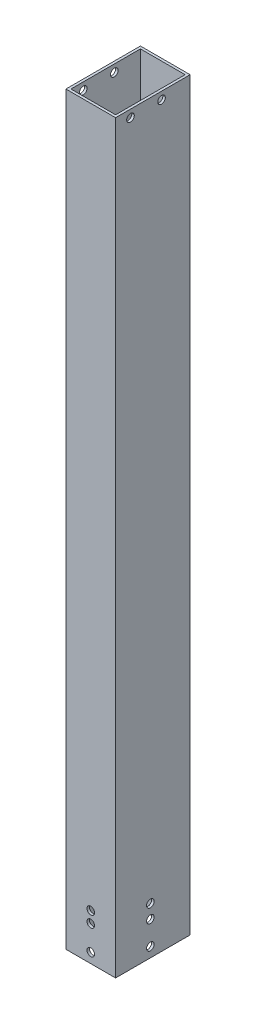
from build123d import *

# Parameters (mm, degrees)
SKETCH_1_W                = 20
SKETCH_1_H                = 30
EXTRUDE_1_DEPTH           = 150
SKETCH_2_W                = 18
SKETCH_2_H                = 28
CUT_EXTRUDE_1_DEPTH       = 301
SKETCH_3_R                = 1.525
CUT_EXTRUDE_2_DEPTH       = 21
SKETCH_4_R                = 1.525
CUT_EXTRUDE_3_DEPTH       = 31
SKETCH_5_R                = 1.525
CUT_EXTRUDE_4_DEPTH       = 31
SKETCH_6_OUTSIDE_W        = 92.432
SKETCH_6_OUTSIDE_H        = 362.432
SKETCH_6_OUTSIDE_W_2      = 30
SKETCH_6_OUTSIDE_H_2      = 300
SKETCH_6_OUTSIDE_R        = 1.525
CUT_EXTRUDE_6_DEPTH       = 21
CUT_EXTRUDE_8_REACH       = 32
SKETCH_9_R                = 1.525
SKETCH_10_R               = 1.525
CUT_EXTRUDE_9_DEPTH       = 1
CUT_EXTRUDE_9_DEPTH_BACK  = 21
SKETCH_11_R               = 1.525
CUT_EXTRUDE_10_DEPTH      = 20
CUT_EXTRUDE_10_DEPTH_BACK = 2


with BuildPart() as part:
    # 草图1 → 凸台-拉伸1 (new body, symmetric)
    with BuildSketch(Plane(origin=(0, 0, 0), x_dir=(1, 0, 0), z_dir=(0, 1, 0))):
        Rectangle(SKETCH_1_W, SKETCH_1_H)
    extrude(amount=EXTRUDE_1_DEPTH, both=True)

    # 草图2 → 切除-拉伸1 (cut, through all)
    with BuildSketch(Plane(origin=(0, 150, 0), x_dir=(1, 0, 0), z_dir=(0, 1, 0))):
        Rectangle(SKETCH_2_W, SKETCH_2_H)
    extrude(amount=-CUT_EXTRUDE_1_DEPTH, mode=Mode.SUBTRACT)

    # 草图3 → 切除-拉伸2 (cut, through all)
    with BuildSketch(Plane(origin=(10, 0, 0), x_dir=(0, 0, -1), z_dir=(1, 0, 0))):
        with Locations((-1, -146)):
            Circle(SKETCH_3_R)
    extrude(amount=-CUT_EXTRUDE_2_DEPTH, mode=Mode.SUBTRACT)

    # 草图4 → 切除-拉伸3 (cut, through all)
    with BuildSketch(Plane.XY.offset(15)):
        with Locations((0, -146)):
            Circle(SKETCH_4_R)
    extrude(amount=-CUT_EXTRUDE_3_DEPTH, mode=Mode.SUBTRACT)

    # 草图5 → 切除-拉伸4 (cut, through all)
    with BuildSketch(Plane.XY.offset(15)):
        with Locations((0, -136)):
            Circle(SKETCH_5_R)
    extrude(amount=-CUT_EXTRUDE_4_DEPTH, mode=Mode.SUBTRACT)

    # 草图6 outside → 切除-拉伸6 (cut, through all)
    with BuildSketch(Plane(origin=(10, 0, 0), x_dir=(0, 0, -1), z_dir=(1, 0, 0))):
        Rectangle(SKETCH_6_OUTSIDE_W, SKETCH_6_OUTSIDE_H)
        Rectangle(SKETCH_6_OUTSIDE_W_2, SKETCH_6_OUTSIDE_H_2, mode=Mode.SUBTRACT)
        with Locations((-1, -131)):
            Circle(SKETCH_6_OUTSIDE_R)
    extrude(amount=-CUT_EXTRUDE_6_DEPTH, mode=Mode.SUBTRACT)

    # 草图9 → 切除-拉伸8 (cut, up to next)
    with BuildSketch(Plane.XY.offset(15), mode=Mode.PRIVATE) as cut_extrude_8_sk1:
        with Locations((0, -131.5)):
            Circle(SKETCH_9_R)
    cut_extrude_8_tool1 = extrude(cut_extrude_8_sk1.sketch, amount=-CUT_EXTRUDE_8_REACH, mode=Mode.PRIVATE) & part.part
    add(cut_extrude_8_tool1.solids().sort_by_distance((0, -131.5, 15))[0], mode=Mode.SUBTRACT)

    # 草图10 → 切除-拉伸9 (cut, two sides)
    with BuildSketch(Plane(origin=(10, 0, 0), x_dir=(0, 0, -1), z_dir=(1, 0, 0))) as cut_extrude_9_sk:
        with Locations((-1, -136.5)):
            Circle(SKETCH_10_R)
    extrude(amount=CUT_EXTRUDE_9_DEPTH, mode=Mode.SUBTRACT)
    extrude(cut_extrude_9_sk.sketch, amount=-CUT_EXTRUDE_9_DEPTH_BACK, mode=Mode.SUBTRACT)

    # 草图11 → 切除-拉伸10 (cut, two sides)
    with BuildSketch(Plane.ZY.offset(-9)) as cut_extrude_10_sk:
        with Locations((9, 147)):
            Circle(SKETCH_11_R)
        with Locations((-3.5, 147)):
            Circle(SKETCH_11_R)
    extrude(amount=CUT_EXTRUDE_10_DEPTH, mode=Mode.SUBTRACT)
    extrude(cut_extrude_10_sk.sketch, amount=-CUT_EXTRUDE_10_DEPTH_BACK, mode=Mode.SUBTRACT)


solid = part.part
